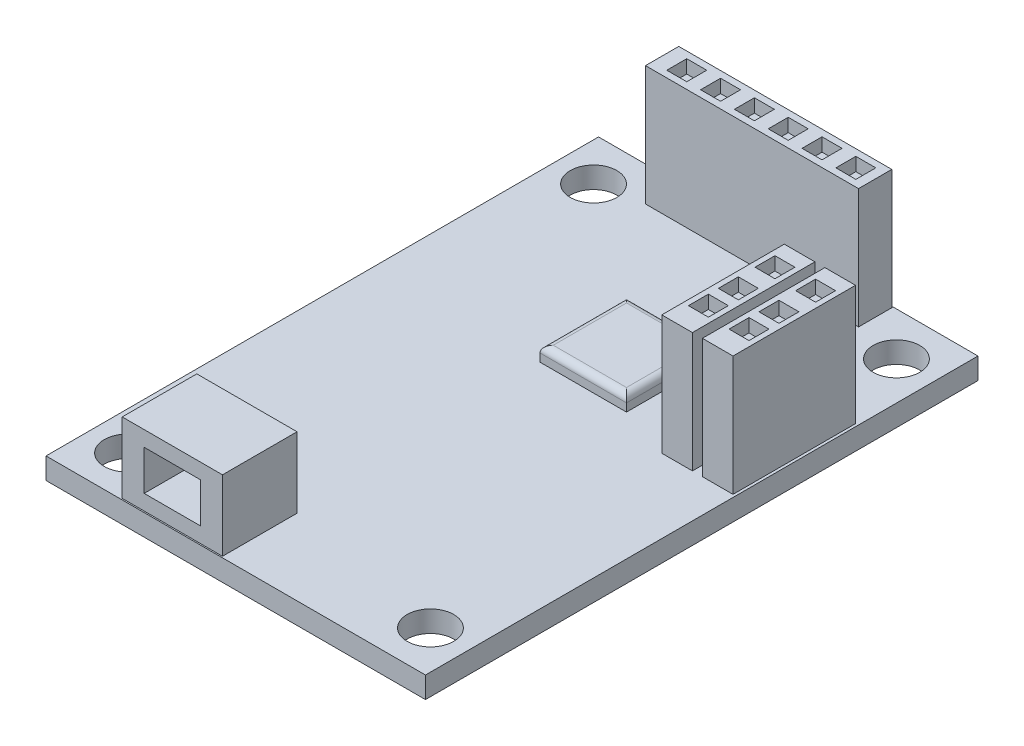
from build123d import *

# Parameters (mm, degrees)
SKETCH1_W           = 28.5
SKETCH1_H           = 41.5
SKETCH1_R           = 1.75
BOSS_EXTRUDE1_DEPTH = 1.6
SKETCH2_W           = 2.3
SKETCH2_H           = 9.2
SKETCH2_W_2         = 16
SKETCH2_H_2         = 2.5
BOSS_EXTRUDE2_DEPTH = 9
SKETCH3_W           = 1.5
SKETCH3_H           = 1.5
CUT_EXTRUDE1_DEPTH  = 1
SKETCH4_W           = 6.5
SKETCH4_H           = 6.5
BOSS_EXTRUDE3_DEPTH = 1.1
FILLET1_R           = 0.5
SKETCH5_W           = 7.53
SKETCH5_H           = 5.6
BOSS_EXTRUDE4_DEPTH = 5.3
SKETCH6_W           = 4.23
SKETCH6_H           = 3
CUT_EXTRUDE2_DEPTH  = 4.5


with BuildPart() as part:
    # Sketch1 → Boss-Extrude1 (new body)
    with BuildSketch(Plane(origin=(0, 0, 0), x_dir=(1, 0, 0), z_dir=(0, 1, 0))):
        Rectangle(SKETCH1_W, SKETCH1_H)
        with Locations((11.375, 17.5)):
            Circle(SKETCH1_R, mode=Mode.SUBTRACT)
        with Locations((-11.375, 17.5)):
            Circle(SKETCH1_R, mode=Mode.SUBTRACT)
        with Locations((-11.375, -17.5)):
            Circle(SKETCH1_R, mode=Mode.SUBTRACT)
        with Locations((11.375, -17.5)):
            Circle(SKETCH1_R, mode=Mode.SUBTRACT)
    extrude(amount=BOSS_EXTRUDE1_DEPTH)

    # Sketch2 → Boss-Extrude2 (add)
    with BuildSketch(Plane(origin=(0, 1.6, 0), x_dir=(1, 0, 0), z_dir=(0, 1, 0))):
        with Locations((12.9, 7.15)):
            Rectangle(SKETCH2_W, SKETCH2_H)
        with Locations((9.85, 7.15)):
            Rectangle(SKETCH2_W, SKETCH2_H)
        with Locations((-0.125, 19.4)):
            Rectangle(SKETCH2_W_2, SKETCH2_H_2)
    extrude(amount=BOSS_EXTRUDE2_DEPTH)

    # Sketch3 → Cut-Extrude1 (cut)
    with BuildSketch(Plane(origin=(0, 10.6, 0), x_dir=(1, 0, 0), z_dir=(0, 1, 0))):
        with Locations((12.9, 7.15)):
            Rectangle(SKETCH3_W, SKETCH3_H)
        with Locations((12.9, 9.9)):
            Rectangle(SKETCH3_W, SKETCH3_H)
        with Locations((12.9, 4.9)):
            Rectangle(SKETCH3_W, SKETCH3_H)
        with Locations((9.85, 4.9)):
            Rectangle(SKETCH3_W, SKETCH3_H)
        with Locations((9.85, 7.15)):
            Rectangle(SKETCH3_W, SKETCH3_H)
        with Locations((9.85, 9.9)):
            Rectangle(SKETCH3_W, SKETCH3_H)
        with Locations((6.425, 19.4)):
            Rectangle(SKETCH3_W, SKETCH3_H)
        with Locations((3.885, 19.4)):
            Rectangle(SKETCH3_W, SKETCH3_H)
        with Locations((1.345, 19.4)):
            Rectangle(SKETCH3_W, SKETCH3_H)
        with Locations((-1.195, 19.4)):
            Rectangle(SKETCH3_W, SKETCH3_H)
        with Locations((-3.735, 19.4)):
            Rectangle(SKETCH3_W, SKETCH3_H)
        with Locations((-6.275, 19.4)):
            Rectangle(SKETCH3_W, SKETCH3_H)
    extrude(amount=-CUT_EXTRUDE1_DEPTH, mode=Mode.SUBTRACT)

    # Sketch4 → Boss-Extrude3 (add)
    with BuildSketch(Plane(origin=(0, 1.6, 0), x_dir=(1, 0, 0), z_dir=(0, 1, 0))):
        with Locations((1.45, 7.15)):
            Rectangle(SKETCH4_W, SKETCH4_H)
    extrude(amount=BOSS_EXTRUDE3_DEPTH)

    # Fillet1
    fillet1_edges = [part.edges().sort_by_distance(p)[0] for p in [
        (4.7, 2.7, -7.15),
        (1.45, 2.7, -10.4),
        (-1.8, 2.7, -7.15),
        (1.45, 2.7, -3.9),
    ]]
    fillet(fillet1_edges, radius=FILLET1_R)

    # Sketch5 → Boss-Extrude4 (add)
    with BuildSketch(Plane(origin=(0, 1.6, 0), x_dir=(1, 0, 0), z_dir=(0, 1, 0))):
        with Locations((-4.86, -17.85)):
            Rectangle(SKETCH5_W, SKETCH5_H)
    extrude(amount=BOSS_EXTRUDE4_DEPTH)

    # Sketch6 → Cut-Extrude2 (cut)
    with BuildSketch(Plane.XY.offset(20.65)):
        with Locations((-4.86, 4.25)):
            Rectangle(SKETCH6_W, SKETCH6_H)
    extrude(amount=-CUT_EXTRUDE2_DEPTH, mode=Mode.SUBTRACT)


solid = part.part
